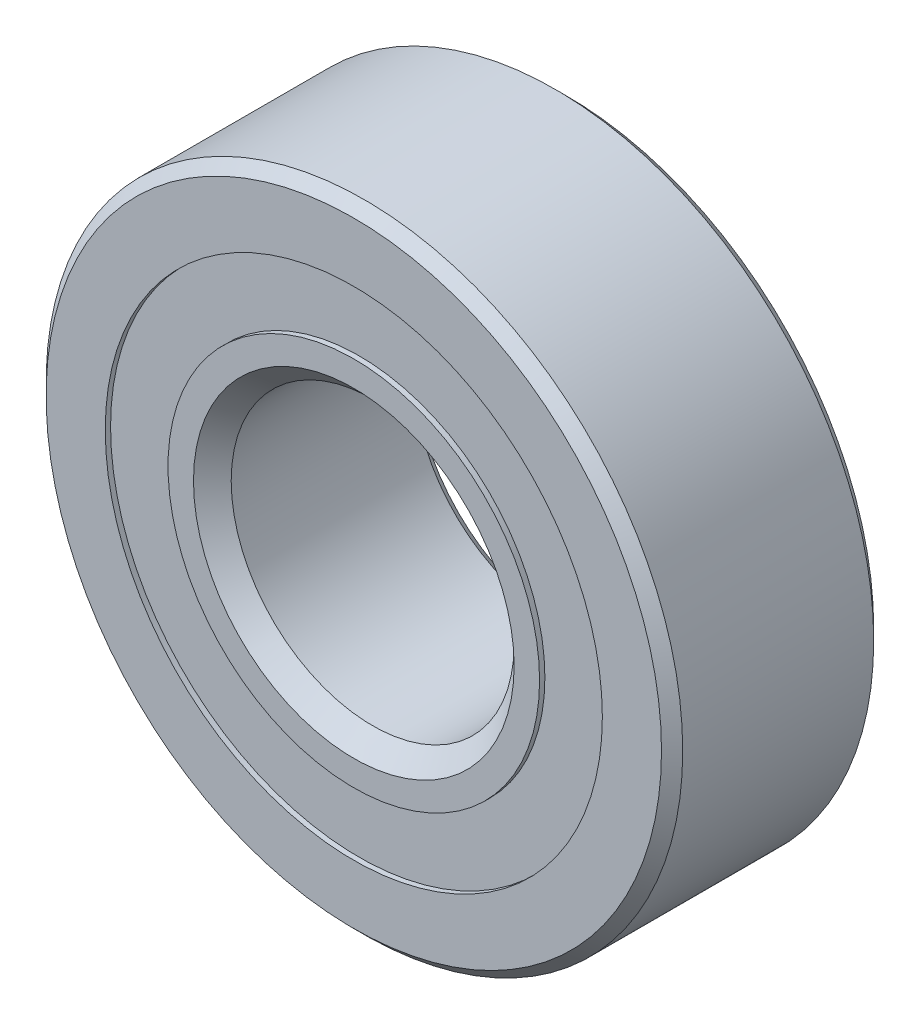
from build123d import *

# Parameters (mm, degrees)
CIRPATTERN1_COUNT = 10
SKETCH5_W         = 2.248094269
SKETCH5_H         = 2.817301638


with BuildPart() as part:
    # Sketch1 → Revolve1 (revolve)
    with BuildSketch(Plane(origin=(0, 0, 0), x_dir=(0, 0, -1), z_dir=(1, 0, 0))):
        with BuildLine():
            Line((4.28625, 14.2875), (-4.28625, 14.2875))
            Line((-4.28625, 14.2875), (-4.7625, 13.81125))
            Line((-4.7625, 13.81125), (-4.7625, 11.156112637))
            Line((-4.7625, 11.156112637), (-2.116666667, 11.156112637))
            ThreePointArc((-2.116666667, 11.156112637), (0, 12.595030731), (2.116666667, 11.156112637))
            Line((2.116666667, 11.156112637), (4.7625, 11.156112637))
            Line((4.7625, 11.156112637), (4.7625, 13.81125))
            Line((4.7625, 13.81125), (4.28625, 14.2875))
        make_face()
    revolve(axis=Axis((0, 0, 4.7625), (0, 0, -1)))


with BuildPart() as body_2:
    # Sketch3 → Revolve3 (revolve)
    with BuildSketch(Plane(origin=(0, 0, 0), x_dir=(0, 0, -1), z_dir=(1, 0, 0))):
        with BuildLine():
            Line((-4.524375, 8.100685999), (-3.619923636, 7.196234635))
            Line((-3.619923636, 7.196234635), (0, 7.196234635))
            Line((0, 7.196234635), (0, 8.042469269))
            ThreePointArc((0, 8.042469269), (1.279722925, 8.436261434), (2.116666667, 9.481387363))
            Line((2.116666667, 9.481387363), (4.7625, 9.481387363))
            Line((4.7625, 9.481387363), (4.7625, 6.82625))
            Line((4.7625, 6.82625), (4.28625, 6.35))
            Line((4.28625, 6.35), (-3.916265365, 6.35))
            Line((-3.916265365, 6.35), (-4.7625, 7.196234635))
            Line((-4.7625, 7.196234635), (-4.7625, 8.338810999))
            Line((-4.7625, 8.338810999), (-4.524375, 8.338810999))
            Line((-4.524375, 8.338810999), (-4.524375, 8.100685999))
        make_face()
    revolve(axis=Axis((0, 0, 4.7625), (0, 0, -1)))


with BuildPart() as body_3:
    # Sketch4 → Revolve4 (revolve)
    with BuildSketch(Plane(origin=(0, 0, 0), x_dir=(0, 0, -1), z_dir=(1, 0, 0))):
        with BuildLine():
            Line((-2.276280731, 10.31875), (2.276280731, 10.31875))
            ThreePointArc((2.276280731, 10.31875), (0, 12.595030731), (-2.276280731, 10.31875))
        make_face()
    revolve(axis=Axis((0, 10.31875, 2.276280731), (0, 0, -1)))


with BuildPart() as cirpattern1_1:
    # CirPattern1: pattern copy
    add(body_3.part.rotate(Axis((0, 0, 0), (0, 0, 1)), 1 * 360 / CIRPATTERN1_COUNT))


with BuildPart() as cirpattern1_2:
    # CirPattern1: pattern copy
    add(body_3.part.rotate(Axis((0, 0, 0), (0, 0, 1)), 2 * 360 / CIRPATTERN1_COUNT))


with BuildPart() as cirpattern1_3:
    # CirPattern1: pattern copy
    add(body_3.part.rotate(Axis((0, 0, 0), (0, 0, 1)), 3 * 360 / CIRPATTERN1_COUNT))


with BuildPart() as cirpattern1_4:
    # CirPattern1: pattern copy
    add(body_3.part.rotate(Axis((0, 0, 0), (0, 0, 1)), 4 * 360 / CIRPATTERN1_COUNT))


with BuildPart() as cirpattern1_5:
    # CirPattern1: pattern copy
    add(body_3.part.rotate(Axis((0, 0, 0), (0, 0, 1)), 5 * 360 / CIRPATTERN1_COUNT))


with BuildPart() as cirpattern1_6:
    # CirPattern1: pattern copy
    add(body_3.part.rotate(Axis((0, 0, 0), (0, 0, 1)), 6 * 360 / CIRPATTERN1_COUNT))


with BuildPart() as cirpattern1_7:
    # CirPattern1: pattern copy
    add(body_3.part.rotate(Axis((0, 0, 0), (0, 0, 1)), 7 * 360 / CIRPATTERN1_COUNT))


with BuildPart() as cirpattern1_8:
    # CirPattern1: pattern copy
    add(body_3.part.rotate(Axis((0, 0, 0), (0, 0, 1)), 8 * 360 / CIRPATTERN1_COUNT))


with BuildPart() as cirpattern1_9:
    # CirPattern1: pattern copy
    add(body_3.part.rotate(Axis((0, 0, 0), (0, 0, 1)), 9 * 360 / CIRPATTERN1_COUNT))


with BuildPart() as body_13:
    # Sketch5 → Revolve5 (revolve)
    with BuildSketch(Plane(origin=(0, 0, 0), x_dir=(0, 0, -1), z_dir=(1, 0, 0))):
        with Locations((-3.400327865, 9.747461818)):
            Rectangle(SKETCH5_W, SKETCH5_H)
        with Locations((3.400327865, 9.747461818)):
            Rectangle(SKETCH5_W, SKETCH5_H)
    revolve(axis=Axis((0, 0, 4.7625), (0, 0, -1)))


solid = Compound([part.part, body_2.part, body_3.part, cirpattern1_1.part, cirpattern1_2.part, cirpattern1_3.part, cirpattern1_4.part, cirpattern1_5.part, cirpattern1_6.part, cirpattern1_7.part, cirpattern1_8.part, cirpattern1_9.part, body_13.part])
